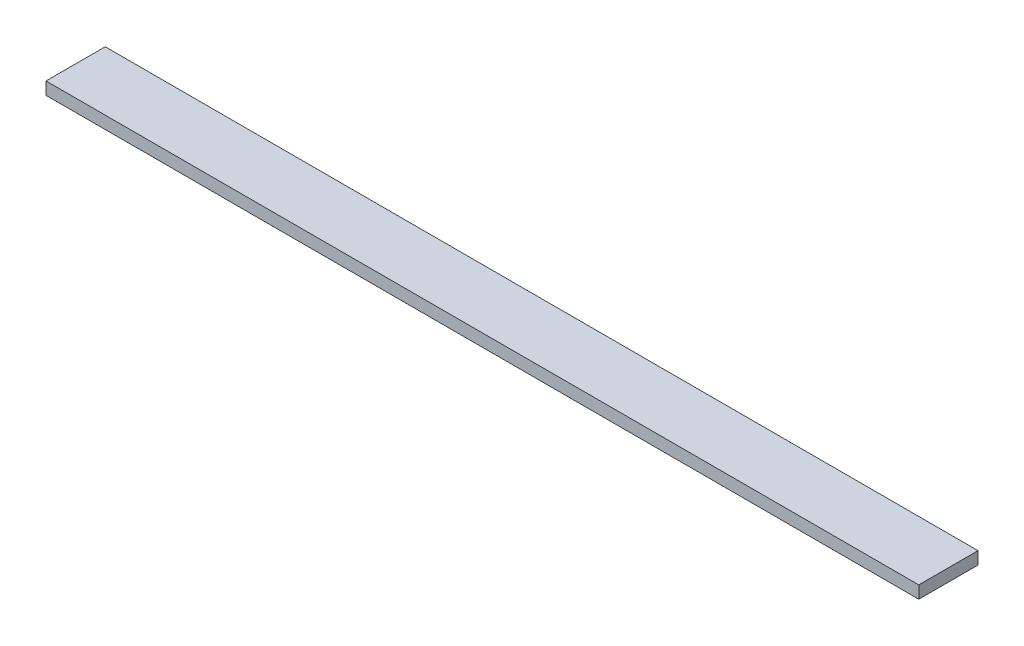
from build123d import *

# Parameters (mm, degrees)
SKETCH1_W           = 177.8
SKETCH1_H           = 12.065
BOSS_EXTRUDE1_DEPTH = 2.54


with BuildPart() as part:
    # Sketch1 → Boss-Extrude1 (new body)
    with BuildSketch(Plane(origin=(0, 0, 0), x_dir=(1, 0, 0), z_dir=(0, 1, 0))):
        with Locations((88.9, 6.0325)):
            Rectangle(SKETCH1_W, SKETCH1_H)
    extrude(amount=BOSS_EXTRUDE1_DEPTH)


solid = part.part
